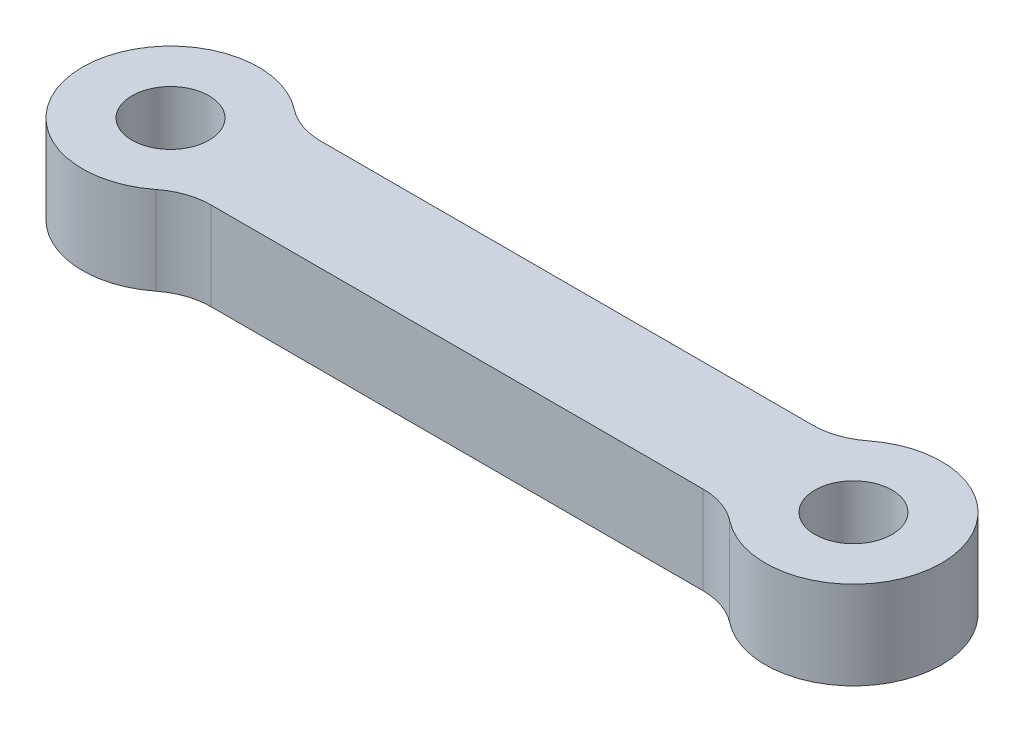
from build123d import *

# Parameters (mm, degrees)
SKETCH1_R           = 1.75
BOSS_EXTRUDE1_DEPTH = 4
FILLET1_R           = 3


with BuildPart() as part:
    # Sketch1 → Boss-Extrude1 (new body)
    with BuildSketch(Plane(origin=(0, 0, 0), x_dir=(1, 0, 0), z_dir=(0, 1, 0))):
        with BuildLine():
            Line((27.877501001, 2.5), (3.122498999, 2.5))
            ThreePointArc((3.122498999, 2.5), (-4, 0), (3.122498999, -2.5))
            Line((3.122498999, -2.5), (27.877501001, -2.5))
            ThreePointArc((27.877501001, -2.5), (35, 0), (27.877501001, 2.5))
        make_face()
        Circle(SKETCH1_R, mode=Mode.SUBTRACT)
        with Locations((31, 0)):
            Circle(SKETCH1_R, mode=Mode.SUBTRACT)
    extrude(amount=BOSS_EXTRUDE1_DEPTH)

    # Fillet1
    fillet1_edges = [part.edges().sort_by_distance(p)[0] for p in [
        (27.877501001, 2, 2.5),
        (3.122498999, 2, 2.5),
        (3.122498999, 2, -2.5),
        (27.877501001, 2, -2.5),
    ]]
    fillet(fillet1_edges, radius=FILLET1_R)


solid = part.part
